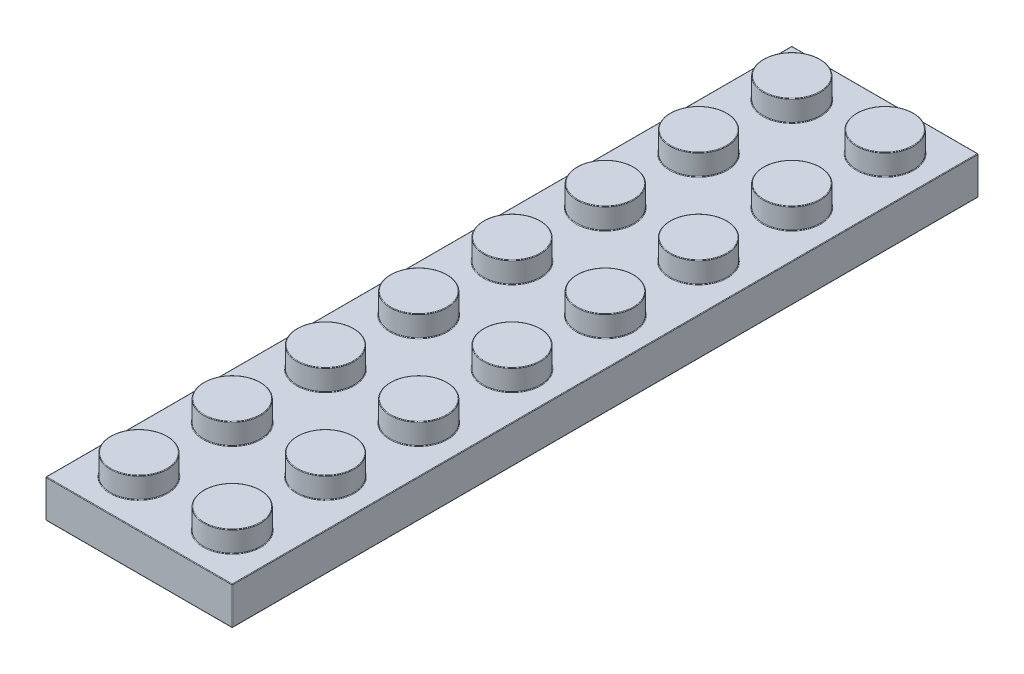
from build123d import *

# Parameters (mm, degrees)
SKETCH1_W                  = 7.96
SKETCH1_H                  = 7.96
EXTRUDE1_DEPTH             = 3.22
SKETCH2_R                  = 2.425
EXTRUDE2_DEPTH             = 1.8
LPATTERN1_COUNT            = 2
LPATTERN1_PITCH            = 7.96
LPATTERN2_COUNT            = 8
LPATTERN2_PITCH            = 7.96
LPATTERN2_COPY_1_SKETCH_W  = 7.96
LPATTERN2_COPY_1_SKETCH_H  = 7.96
LPATTERN2_COPY_1_DEPTH     = 3.22
LPATTERN2_COPY_2_SKETCH_W  = 7.96
LPATTERN2_COPY_2_SKETCH_H  = 7.96
LPATTERN2_COPY_2_DEPTH     = 3.22
LPATTERN2_COPY_3_SKETCH_W  = 7.96
LPATTERN2_COPY_3_SKETCH_H  = 7.96
LPATTERN2_COPY_3_DEPTH     = 3.22
LPATTERN2_COPY_4_SKETCH_W  = 7.96
LPATTERN2_COPY_4_SKETCH_H  = 7.96
LPATTERN2_COPY_4_DEPTH     = 3.22
LPATTERN2_COPY_5_SKETCH_W  = 7.96
LPATTERN2_COPY_5_SKETCH_H  = 7.96
LPATTERN2_COPY_5_DEPTH     = 3.22
LPATTERN2_COPY_6_SKETCH_W  = 7.96
LPATTERN2_COPY_6_SKETCH_H  = 7.96
LPATTERN2_COPY_6_DEPTH     = 3.22
LPATTERN2_COPY_7_SKETCH_W  = 7.96
LPATTERN2_COPY_7_SKETCH_H  = 7.96
LPATTERN2_COPY_7_DEPTH     = 3.22
LPATTERN2_COPY_8_SKETCH_R  = 2.425
LPATTERN2_COPY_8_DEPTH     = 1.8
LPATTERN2_COPY_9_SKETCH_R  = 2.425
LPATTERN2_COPY_9_DEPTH     = 1.8
LPATTERN2_COPY_10_SKETCH_R = 2.425
LPATTERN2_COPY_10_DEPTH    = 1.8
LPATTERN2_COPY_11_SKETCH_R = 2.425
LPATTERN2_COPY_11_DEPTH    = 1.8
LPATTERN2_COPY_12_SKETCH_R = 2.425
LPATTERN2_COPY_12_DEPTH    = 1.8
LPATTERN2_COPY_13_SKETCH_R = 2.425
LPATTERN2_COPY_13_DEPTH    = 1.8
LPATTERN2_COPY_14_SKETCH_R = 2.425
LPATTERN2_COPY_14_DEPTH    = 1.8
SHELL1_T                   = -1.55
SKETCH3_W                  = 12.82
SKETCH3_H                  = 60.58
EXTRUDE3_DEPTH             = 0.14
SKETCH4_R                  = 3.23
SKETCH4_R_2                = 2.37
EXTRUDE4_DEPTH             = 1.81
FILLET1_R                  = 0.05


with BuildPart() as part:
    # Sketch1 → Extrude1 (new body)
    with BuildSketch(Plane(origin=(0, 0, 0), x_dir=(1, 0, 0), z_dir=(0, 1, 0))):
        Rectangle(SKETCH1_W, SKETCH1_H)
    extrude1 = extrude(amount=EXTRUDE1_DEPTH)

    # Sketch2 → Extrude2 (add)
    with BuildSketch(Plane(origin=(0, 3.22, 0), x_dir=(1, 0, 0), z_dir=(0, 1, 0))):
        Circle(SKETCH2_R)
    extrude2 = extrude(amount=EXTRUDE2_DEPTH)

    # LPattern1: Extrude1, Extrude2 ×2
    with Locations(*[(-i * LPATTERN1_PITCH, 0, 0) for i in range(1, LPATTERN1_COUNT)]):
        add(extrude1)
        add(extrude2)

    # LPattern2: Extrude2, Extrude1 ×8
    with Locations(*[(0, 0, -i * LPATTERN2_PITCH) for i in range(1, LPATTERN2_COUNT)]):
        add(extrude2)
        add(extrude1)

    # LPattern2 copy 1 sketch → LPattern2 copy 1 (add)
    with BuildSketch(Plane(origin=(-7.96, 0, -7.96), x_dir=(1, 0, 0), z_dir=(0, 1, 0))):
        Rectangle(LPATTERN2_COPY_1_SKETCH_W, LPATTERN2_COPY_1_SKETCH_H)
    extrude(amount=LPATTERN2_COPY_1_DEPTH)

    # LPattern2 copy 2 sketch → LPattern2 copy 2 (add)
    with BuildSketch(Plane(origin=(-7.96, 0, -15.92), x_dir=(1, 0, 0), z_dir=(0, 1, 0))):
        Rectangle(LPATTERN2_COPY_2_SKETCH_W, LPATTERN2_COPY_2_SKETCH_H)
    extrude(amount=LPATTERN2_COPY_2_DEPTH)

    # LPattern2 copy 3 sketch → LPattern2 copy 3 (add)
    with BuildSketch(Plane(origin=(-7.96, 0, -23.88), x_dir=(1, 0, 0), z_dir=(0, 1, 0))):
        Rectangle(LPATTERN2_COPY_3_SKETCH_W, LPATTERN2_COPY_3_SKETCH_H)
    extrude(amount=LPATTERN2_COPY_3_DEPTH)

    # LPattern2 copy 4 sketch → LPattern2 copy 4 (add)
    with BuildSketch(Plane(origin=(-7.96, 0, -31.84), x_dir=(1, 0, 0), z_dir=(0, 1, 0))):
        Rectangle(LPATTERN2_COPY_4_SKETCH_W, LPATTERN2_COPY_4_SKETCH_H)
    extrude(amount=LPATTERN2_COPY_4_DEPTH)

    # LPattern2 copy 5 sketch → LPattern2 copy 5 (add)
    with BuildSketch(Plane(origin=(-7.96, 0, -39.8), x_dir=(1, 0, 0), z_dir=(0, 1, 0))):
        Rectangle(LPATTERN2_COPY_5_SKETCH_W, LPATTERN2_COPY_5_SKETCH_H)
    extrude(amount=LPATTERN2_COPY_5_DEPTH)

    # LPattern2 copy 6 sketch → LPattern2 copy 6 (add)
    with BuildSketch(Plane(origin=(-7.96, 0, -47.76), x_dir=(1, 0, 0), z_dir=(0, 1, 0))):
        Rectangle(LPATTERN2_COPY_6_SKETCH_W, LPATTERN2_COPY_6_SKETCH_H)
    extrude(amount=LPATTERN2_COPY_6_DEPTH)

    # LPattern2 copy 7 sketch → LPattern2 copy 7 (add)
    with BuildSketch(Plane(origin=(-7.96, 0, -55.72), x_dir=(1, 0, 0), z_dir=(0, 1, 0))):
        Rectangle(LPATTERN2_COPY_7_SKETCH_W, LPATTERN2_COPY_7_SKETCH_H)
    extrude(amount=LPATTERN2_COPY_7_DEPTH)

    # LPattern2 copy 8 sketch → LPattern2 copy 8 (add)
    with BuildSketch(Plane(origin=(-7.96, 3.22, -7.96), x_dir=(1, 0, 0), z_dir=(0, 1, 0))):
        Circle(LPATTERN2_COPY_8_SKETCH_R)
    extrude(amount=LPATTERN2_COPY_8_DEPTH)

    # LPattern2 copy 9 sketch → LPattern2 copy 9 (add)
    with BuildSketch(Plane(origin=(-7.96, 3.22, -15.92), x_dir=(1, 0, 0), z_dir=(0, 1, 0))):
        Circle(LPATTERN2_COPY_9_SKETCH_R)
    extrude(amount=LPATTERN2_COPY_9_DEPTH)

    # LPattern2 copy 10 sketch → LPattern2 copy 10 (add)
    with BuildSketch(Plane(origin=(-7.96, 3.22, -23.88), x_dir=(1, 0, 0), z_dir=(0, 1, 0))):
        Circle(LPATTERN2_COPY_10_SKETCH_R)
    extrude(amount=LPATTERN2_COPY_10_DEPTH)

    # LPattern2 copy 11 sketch → LPattern2 copy 11 (add)
    with BuildSketch(Plane(origin=(-7.96, 3.22, -31.84), x_dir=(1, 0, 0), z_dir=(0, 1, 0))):
        Circle(LPATTERN2_COPY_11_SKETCH_R)
    extrude(amount=LPATTERN2_COPY_11_DEPTH)

    # LPattern2 copy 12 sketch → LPattern2 copy 12 (add)
    with BuildSketch(Plane(origin=(-7.96, 3.22, -39.8), x_dir=(1, 0, 0), z_dir=(0, 1, 0))):
        Circle(LPATTERN2_COPY_12_SKETCH_R)
    extrude(amount=LPATTERN2_COPY_12_DEPTH)

    # LPattern2 copy 13 sketch → LPattern2 copy 13 (add)
    with BuildSketch(Plane(origin=(-7.96, 3.22, -47.76), x_dir=(1, 0, 0), z_dir=(0, 1, 0))):
        Circle(LPATTERN2_COPY_13_SKETCH_R)
    extrude(amount=LPATTERN2_COPY_13_DEPTH)

    # LPattern2 copy 14 sketch → LPattern2 copy 14 (add)
    with BuildSketch(Plane(origin=(-7.96, 3.22, -55.72), x_dir=(1, 0, 0), z_dir=(0, 1, 0))):
        Circle(LPATTERN2_COPY_14_SKETCH_R)
    extrude(amount=LPATTERN2_COPY_14_DEPTH)

    # Shell1
    shell1_openings = [part.faces().sort_by_distance(p)[0] for p in [
        (-3.98, 0, -27.86),
    ]]
    offset(amount=SHELL1_T, openings=shell1_openings, kind=Kind.INTERSECTION)

    # Sketch3 → Extrude3 (cut)
    with BuildSketch(Plane.XZ.offset(-1.67)):
        with Locations((-3.98, -27.86)):
            Rectangle(SKETCH3_W, SKETCH3_H)
    extrude(amount=-EXTRUDE3_DEPTH, mode=Mode.SUBTRACT)

    # Sketch4 → Extrude4 (add)
    with BuildSketch(Plane.XZ.offset(-1.81)):
        with Locations((-3.98, -51.74)):
            Circle(SKETCH4_R)
        with Locations((-3.98, -51.74)):
            Circle(SKETCH4_R_2, mode=Mode.SUBTRACT)
        with Locations((-3.98, -43.78)):
            Circle(SKETCH4_R)
        with Locations((-3.98, -43.78)):
            Circle(SKETCH4_R_2, mode=Mode.SUBTRACT)
        with Locations((-3.98, -35.82)):
            Circle(SKETCH4_R)
        with Locations((-3.98, -35.82)):
            Circle(SKETCH4_R_2, mode=Mode.SUBTRACT)
        with Locations((-3.98, -27.86)):
            Circle(SKETCH4_R)
        with Locations((-3.98, -27.86)):
            Circle(SKETCH4_R_2, mode=Mode.SUBTRACT)
        with Locations((-3.98, -19.9)):
            Circle(SKETCH4_R)
        with Locations((-3.98, -19.9)):
            Circle(SKETCH4_R_2, mode=Mode.SUBTRACT)
        with Locations((-3.98, -11.94)):
            Circle(SKETCH4_R)
        with Locations((-3.98, -11.94)):
            Circle(SKETCH4_R_2, mode=Mode.SUBTRACT)
        with Locations((-3.98, -3.98)):
            Circle(SKETCH4_R)
        with Locations((-3.98, -3.98)):
            Circle(SKETCH4_R_2, mode=Mode.SUBTRACT)
    extrude(amount=EXTRUDE4_DEPTH)

    # Fillet1
    fillet1_edges = [part.edges().sort_by_distance(p)[0] for p in [
        (-10.385, 3.22, -23.88),
        (-10.385, 5.02, -23.88),
        (-10.385, 3.22, -31.84),
        (-10.385, 5.02, -31.84),
        (-3.98, 3.22, 3.98),
        (-2.425, 3.22, 0),
        (-2.425, 5.02, 0),
        (-10.385, 3.22, -39.8),
        (-10.385, 5.02, -39.8),
        (-10.385, 3.22, -47.76),
        (-10.385, 5.02, -47.76),
        (-11.94, 1.61, -59.7),
        (-10.385, 3.22, -55.72),
        (-10.385, 5.02, -55.72),
        (-11.94, 0, -27.86),
        (2.43, 0, -27.86),
        (2.43, 0.905, 2.43),
        (-3.98, 0, 2.43),
        (-10.39, 0.905, 2.43),
        (-0.875, 3.47, 0),
        (-10.39, 0, -27.86),
        (-10.39, 0.905, -58.15),
        (-8.835, 3.47, 0),
        (-3.98, 0, -58.15),
        (2.43, 0.905, -58.15),
        (-0.875, 3.47, -7.96),
        (-0.875, 3.47, -15.92),
        (-0.875, 3.47, -23.88),
        (-0.875, 3.47, -31.84),
        (-0.875, 3.47, -39.8),
        (-0.875, 3.47, -47.76),
        (-0.875, 3.47, -55.72),
        (-8.835, 3.47, -7.96),
        (-8.835, 3.47, -15.92),
        (-8.835, 3.47, -23.88),
        (-8.835, 3.47, -31.84),
        (-8.835, 3.47, -39.8),
        (-8.835, 3.47, -47.76),
        (-8.835, 3.47, -55.72),
        (-11.94, 1.61, 3.98),
        (-11.94, 3.22, -27.86),
        (-0.875, 1.81, 0),
        (-8.835, 1.81, 0),
        (-0.875, 1.81, -7.96),
        (-0.875, 1.81, -15.92),
        (-0.875, 1.81, -23.88),
        (-0.875, 1.81, -31.84),
        (-0.875, 1.81, -39.8),
        (-0.875, 1.81, -47.76),
        (-0.875, 1.81, -55.72),
        (-8.835, 1.81, -7.96),
        (-8.835, 1.81, -15.92),
        (-8.835, 1.81, -23.88),
        (-8.835, 1.81, -31.84),
        (-8.835, 1.81, -39.8),
        (-8.835, 1.81, -47.76),
        (-8.835, 1.81, -55.72),
        (2.43, 1.81, -27.86),
        (-3.98, 1.81, -58.15),
        (-10.39, 1.81, -27.86),
        (-3.98, 1.81, 2.43),
        (-7.21, 1.81, -51.74),
        (-6.35, 1.81, -51.74),
        (-7.21, 0, -51.74),
        (-6.35, 0, -51.74),
        (-7.21, 1.81, -43.78),
        (-6.35, 1.81, -43.78),
        (-7.21, 0, -43.78),
        (-6.35, 0, -43.78),
        (-7.21, 1.81, -35.82),
        (-6.35, 1.81, -35.82),
        (-7.21, 0, -35.82),
        (-6.35, 0, -35.82),
        (-7.21, 1.81, -27.86),
        (-6.35, 1.81, -27.86),
        (-7.21, 0, -27.86),
        (-10.385, 3.22, 0),
        (-6.35, 0, -27.86),
        (-10.385, 5.02, 0),
        (-7.21, 1.81, -19.9),
        (-6.35, 1.81, -19.9),
        (-7.21, 0, -19.9),
        (-6.35, 0, -19.9),
        (-7.21, 1.81, -11.94),
        (-6.35, 1.81, -11.94),
        (-7.21, 0, -11.94),
        (-6.35, 0, -11.94),
        (-7.21, 1.81, -3.98),
        (-6.35, 1.81, -3.98),
        (-7.21, 0, -3.98),
        (-6.35, 0, -3.98),
        (-3.98, 3.22, -59.7),
        (-3.98, 0, -59.7),
        (3.98, 1.61, -59.7),
        (3.98, 3.22, -27.86),
        (-3.98, 0, 3.98),
        (-2.425, 3.22, -7.96),
        (-2.425, 5.02, -7.96),
        (-2.425, 3.22, -15.92),
        (-2.425, 5.02, -15.92),
        (-2.425, 3.22, -23.88),
        (-2.425, 5.02, -23.88),
        (-2.425, 3.22, -31.84),
        (-2.425, 5.02, -31.84),
        (-2.425, 3.22, -39.8),
        (-2.425, 5.02, -39.8),
        (-2.425, 3.22, -47.76),
        (-2.425, 5.02, -47.76),
        (3.98, 0, -27.86),
        (-2.425, 3.22, -55.72),
        (-2.425, 5.02, -55.72),
        (3.98, 1.61, 3.98),
        (-10.385, 3.22, -7.96),
        (-10.385, 5.02, -7.96),
        (-10.385, 3.22, -15.92),
        (-10.385, 5.02, -15.92),
    ]]
    fillet(fillet1_edges, radius=FILLET1_R)


solid = part.part
